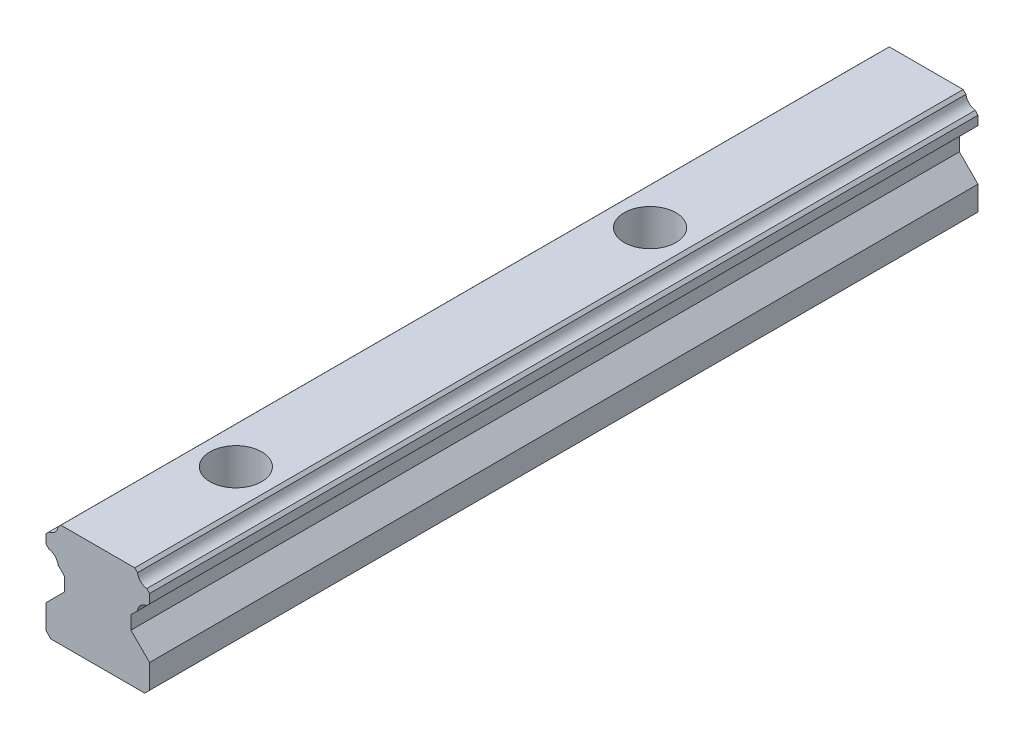
from build123d import *

# Parameters (mm, degrees)
EXTRUDE1_DEPTH  = 120
LPATTERN1_COUNT = 2
LPATTERN1_PITCH = 60


with BuildPart() as part:
    # Sketch1 → Extrude1 (new body)
    with BuildSketch(Plane(origin=(-20, 0, 0), x_dir=(1, 0, 0), z_dir=(0, 0, 1))):
        with BuildLine():
            Line((12.5, 0.69999271), (13.199992786, 0))
            Line((13.199992786, 0), (26.800007214, 0))
            Line((26.800007214, 0), (27.5, 0.69999271))
            Line((27.5, 0.69999271), (27.5, 4.2000246))
            Line((27.5, 4.2000246), (24.8000183, 6.9000063))
            Line((24.8000183, 6.9000063), (24.8000183, 8.8400054))
            Line((24.8000183, 8.8400054), (25.755946813, 9.794179118))
            ThreePointArc((25.755946813, 9.794179118), (26.198484624, 10.690600567), (27.09432569, 11.13431209))
            Line((27.09432569, 11.13431209), (27.5, 11.5399866))
            Line((27.5, 11.5399866), (27.5, 12.8500204))
            Line((27.5, 12.8500204), (27.09432569, 13.268442751))
            ThreePointArc((27.09432569, 13.268442751), (26.202460867, 13.706434947), (25.755946813, 14.594063938))
            Line((25.755946813, 14.594063938), (25.3500197, 15))
            Line((25.3500197, 15), (14.6499803, 15))
            Line((14.6499803, 15), (14.244053187, 14.594063938))
            ThreePointArc((14.244053187, 14.594063938), (13.797539133, 13.706434947), (12.90567431, 13.268442751))
            Line((12.90567431, 13.268442751), (12.5, 12.8500204))
            Line((12.5, 12.8500204), (12.5, 11.5399866))
            Line((12.5, 11.5399866), (12.90567431, 11.13431209))
            ThreePointArc((12.90567431, 11.13431209), (13.801515376, 10.690600567), (14.244053187, 9.794179118))
            Line((14.244053187, 9.794179118), (15.1999817, 8.8400054))
            Line((15.1999817, 8.8400054), (15.1999817, 6.9000063))
            Line((15.1999817, 6.9000063), (12.5, 4.2000246))
            Line((12.5, 4.2000246), (12.5, 0.69999271))
        make_face()
    extrude(amount=-EXTRUDE1_DEPTH)

    # Sketch2 → Cut-Revolve1 (revolve, cut)
    with BuildSketch(Plane(origin=(0, 0, 0), x_dir=(0, 0, -1), z_dir=(1, 0, 0))):
        Polygon((20, 15), (23.75, 15), (23.75, 9.7), (22.25, 9.7), (22.25, 0), (20, 0), align=None)
    cut_revolve1 = revolve(axis=Axis((0, 0, -20), (0, 1, 0)), mode=Mode.SUBTRACT)

    # LPattern1: Cut-Revolve1 ×2
    with Locations(*[(0, 0, -i * LPATTERN1_PITCH) for i in range(1, LPATTERN1_COUNT)]):
        add(cut_revolve1, mode=Mode.SUBTRACT)


solid = part.part
